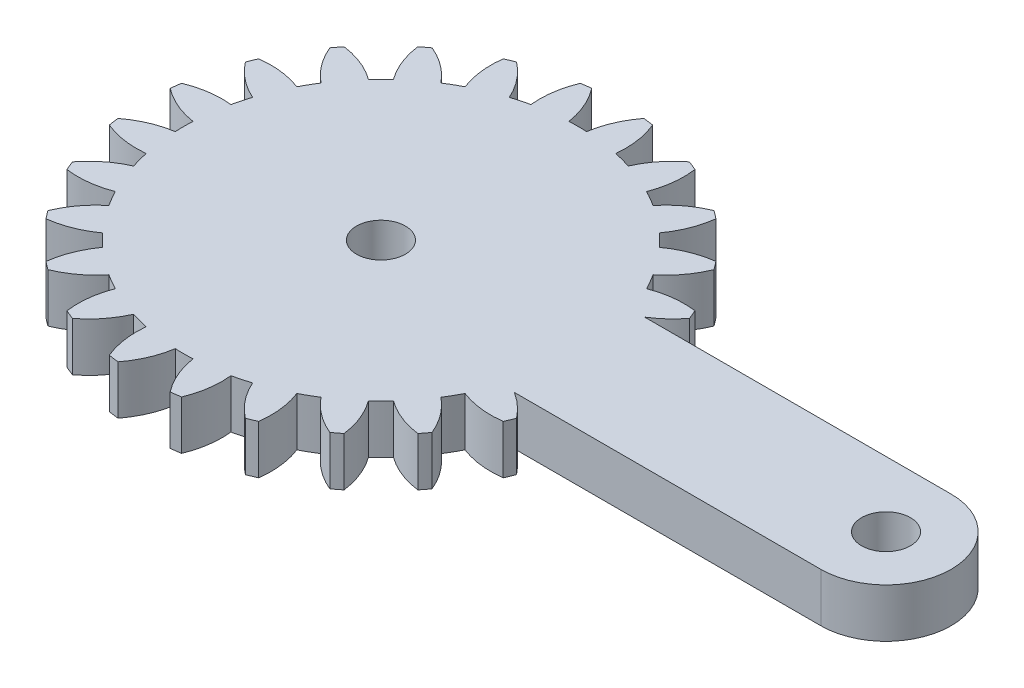
from build123d import *

# Parameters (mm, degrees)
SKETCH1_R           = 1.5
BOSS_EXTRUDE2_DEPTH = 3


with BuildPart() as part:
    # Sketch1 → Boss-Extrude2 (new body)
    with BuildSketch(Plane(origin=(0, 0, 0), x_dir=(1, 0, 0), z_dir=(0, 1, 0))):
        with BuildLine():
            Line((12.18798449, -4), (31, -4))
            ThreePointArc((31, -4), (35, 0), (31, 4))
            Line((31, 4), (12.18798449, 4))
            ThreePointArc((12.18798449, 4), (12.967370887, 4.588201733), (13.62809199, 5.30713988))
            ThreePointArc((13.62809199, 5.30713988), (13.511738163, 5.596745198), (13.389230859, 5.883801663))
            ThreePointArc((13.389230859, 5.883801663), (12.041618533, 5.894040025), (10.733437515, 5.57027124))
            ThreePointArc((10.733437515, 5.57027124), (10.472628702, 6.046375), (10.190715157, 6.510293938))
            ThreePointArc((10.190715157, 6.510293938), (11.125197659, 7.48132754), (11.79013714, 8.65351323))
            ThreePointArc((11.79013714, 8.65351323), (11.602792602, 8.903135899), (11.410163953, 9.148703928))
            ThreePointArc((11.410163953, 9.148703928), (10.105820521, 8.809805691), (8.926012217, 8.158486898))
            ThreePointArc((8.926012217, 8.158486898), (8.550865528, 8.550865528), (8.158486898, 8.926012217))
            ThreePointArc((8.158486898, 8.926012217), (8.809805691, 10.105820521), (9.148703928, 11.410163953))
            ThreePointArc((9.148703928, 11.410163953), (8.903135899, 11.602792602), (8.65351323, 11.79013714))
            ThreePointArc((8.65351323, 11.79013714), (7.48132754, 11.125197659), (6.510293938, 10.190715157))
            ThreePointArc((6.510293938, 10.190715157), (6.046375, 10.472628702), (5.57027124, 10.733437514))
            ThreePointArc((5.57027124, 10.733437514), (5.894040025, 12.041618533), (5.883801663, 13.389230859))
            ThreePointArc((5.883801663, 13.389230859), (5.596745198, 13.511738163), (5.30713988, 13.62809199))
            ThreePointArc((5.30713988, 13.62809199), (4.346994451, 12.682425791), (3.650909885, 11.528463019))
            ThreePointArc((3.650909885, 11.528463019), (3.129834008, 11.680699536), (2.602450802, 11.809396783))
            ThreePointArc((2.602450802, 11.809396783), (2.576605271, 13.156800143), (2.217928037, 14.455843809))
            ThreePointArc((2.217928037, 14.455843809), (1.908945561, 14.499881098), (1.599093719, 14.537314892))
            ThreePointArc((1.599093719, 14.537314892), (0.916420874, 13.375367565), (0.542722358, 12.080565177))
            ThreePointArc((0.542722358, 12.080565177), (0, 12.09275), (-0.542722358, 12.080565177))
            ThreePointArc((-0.542722358, 12.080565177), (-0.916420874, 13.375367565), (-1.599093719, 14.537314892))
            ThreePointArc((-1.599093719, 14.537314892), (-1.908945561, 14.499881098), (-2.217928037, 14.455843809))
            ThreePointArc((-2.217928037, 14.455843809), (-2.576605271, 13.156800143), (-2.602450802, 11.809396783))
            ThreePointArc((-2.602450802, 11.809396783), (-3.129834008, 11.680699536), (-3.650909885, 11.528463019))
            ThreePointArc((-3.650909885, 11.528463019), (-4.346994451, 12.682425791), (-5.30713988, 13.62809199))
            ThreePointArc((-5.30713988, 13.62809199), (-5.596745198, 13.511738163), (-5.883801663, 13.389230859))
            ThreePointArc((-5.883801663, 13.389230859), (-5.894040025, 12.041618533), (-5.57027124, 10.733437514))
            ThreePointArc((-5.57027124, 10.733437514), (-6.046375, 10.472628702), (-6.510293938, 10.190715157))
            ThreePointArc((-6.510293938, 10.190715157), (-7.48132754, 11.125197659), (-8.65351323, 11.79013714))
            ThreePointArc((-8.65351323, 11.79013714), (-8.903135899, 11.602792602), (-9.148703928, 11.410163953))
            ThreePointArc((-9.148703928, 11.410163953), (-8.809805691, 10.105820521), (-8.158486898, 8.926012217))
            ThreePointArc((-8.158486898, 8.926012217), (-8.550865528, 8.550865528), (-8.926012217, 8.158486898))
            ThreePointArc((-8.926012217, 8.158486898), (-10.105820521, 8.809805691), (-11.410163953, 9.148703928))
            ThreePointArc((-11.410163953, 9.148703928), (-11.602792602, 8.903135899), (-11.79013714, 8.65351323))
            ThreePointArc((-11.79013714, 8.65351323), (-11.125197659, 7.48132754), (-10.190715157, 6.510293938))
            ThreePointArc((-10.190715157, 6.510293938), (-10.472628702, 6.046375), (-10.733437515, 5.57027124))
            ThreePointArc((-10.733437515, 5.57027124), (-12.041618533, 5.894040025), (-13.389230859, 5.883801663))
            ThreePointArc((-13.389230859, 5.883801663), (-13.511738163, 5.596745198), (-13.62809199, 5.30713988))
            ThreePointArc((-13.62809199, 5.30713988), (-12.682425791, 4.346994451), (-11.528463019, 3.650909885))
            ThreePointArc((-11.528463019, 3.650909885), (-11.680699536, 3.129834008), (-11.809396783, 2.602450801))
            ThreePointArc((-11.809396783, 2.602450801), (-13.156800143, 2.576605271), (-14.455843809, 2.217928037))
            ThreePointArc((-14.455843809, 2.217928037), (-14.499881098, 1.908945561), (-14.537314892, 1.599093719))
            ThreePointArc((-14.537314892, 1.599093719), (-13.375367565, 0.916420874), (-12.080565177, 0.542722358))
            ThreePointArc((-12.080565177, 0.542722358), (-12.09275, 0), (-12.080565177, -0.542722358))
            ThreePointArc((-12.080565177, -0.542722358), (-13.375367565, -0.916420874), (-14.537314892, -1.599093719))
            ThreePointArc((-14.537314892, -1.599093719), (-14.499881098, -1.908945561), (-14.455843809, -2.217928037))
            ThreePointArc((-14.455843809, -2.217928037), (-13.156800143, -2.576605271), (-11.809396783, -2.602450801))
            ThreePointArc((-11.809396783, -2.602450801), (-11.680699536, -3.129834008), (-11.528463019, -3.650909885))
            ThreePointArc((-11.528463019, -3.650909885), (-12.682425791, -4.346994451), (-13.62809199, -5.30713988))
            ThreePointArc((-13.62809199, -5.30713988), (-13.511738163, -5.596745198), (-13.389230859, -5.883801663))
            ThreePointArc((-13.389230859, -5.883801663), (-12.041618533, -5.894040025), (-10.733437515, -5.57027124))
            ThreePointArc((-10.733437515, -5.57027124), (-10.472628702, -6.046375), (-10.190715157, -6.510293938))
            ThreePointArc((-10.190715157, -6.510293938), (-11.125197659, -7.48132754), (-11.79013714, -8.65351323))
            ThreePointArc((-11.79013714, -8.65351323), (-11.602792602, -8.903135899), (-11.410163953, -9.148703928))
            ThreePointArc((-11.410163953, -9.148703928), (-10.105820521, -8.809805691), (-8.926012217, -8.158486898))
            ThreePointArc((-8.926012217, -8.158486898), (-8.550865528, -8.550865528), (-8.158486898, -8.926012217))
            ThreePointArc((-8.158486898, -8.926012217), (-8.809805691, -10.105820521), (-9.148703928, -11.410163953))
            ThreePointArc((-9.148703928, -11.410163953), (-8.903135899, -11.602792602), (-8.65351323, -11.79013714))
            ThreePointArc((-8.65351323, -11.79013714), (-7.48132754, -11.125197659), (-6.510293938, -10.190715157))
            ThreePointArc((-6.510293938, -10.190715157), (-6.046375, -10.472628702), (-5.57027124, -10.733437514))
            ThreePointArc((-5.57027124, -10.733437514), (-5.894040025, -12.041618533), (-5.883801663, -13.389230859))
            ThreePointArc((-5.883801663, -13.389230859), (-5.596745198, -13.511738163), (-5.30713988, -13.62809199))
            ThreePointArc((-5.30713988, -13.62809199), (-4.346994451, -12.682425791), (-3.650909885, -11.528463019))
            ThreePointArc((-3.650909885, -11.528463019), (-3.129834008, -11.680699536), (-2.602450802, -11.809396783))
            ThreePointArc((-2.602450802, -11.809396783), (-2.576605271, -13.156800143), (-2.217928037, -14.455843809))
            ThreePointArc((-2.217928037, -14.455843809), (-1.908945561, -14.499881098), (-1.599093719, -14.537314892))
            ThreePointArc((-1.599093719, -14.537314892), (-0.916420874, -13.375367565), (-0.542722358, -12.080565177))
            ThreePointArc((-0.542722358, -12.080565177), (0, -12.09275), (0.542722358, -12.080565177))
            ThreePointArc((0.542722358, -12.080565177), (0.916420874, -13.375367565), (1.599093719, -14.537314892))
            ThreePointArc((1.599093719, -14.537314892), (1.908945561, -14.499881098), (2.217928037, -14.455843809))
            ThreePointArc((2.217928037, -14.455843809), (2.576605271, -13.156800143), (2.602450802, -11.809396783))
            ThreePointArc((2.602450802, -11.809396783), (3.129834008, -11.680699536), (3.650909885, -11.528463019))
            ThreePointArc((3.650909885, -11.528463019), (4.346994451, -12.682425791), (5.30713988, -13.62809199))
            ThreePointArc((5.30713988, -13.62809199), (5.596745198, -13.511738163), (5.883801663, -13.389230859))
            ThreePointArc((5.883801663, -13.389230859), (5.894040025, -12.041618533), (5.57027124, -10.733437514))
            ThreePointArc((5.57027124, -10.733437514), (6.046375, -10.472628702), (6.510293938, -10.190715157))
            ThreePointArc((6.510293938, -10.190715157), (7.48132754, -11.125197659), (8.65351323, -11.79013714))
            ThreePointArc((8.65351323, -11.79013714), (8.903135899, -11.602792602), (9.148703928, -11.410163953))
            ThreePointArc((9.148703928, -11.410163953), (8.809805691, -10.105820521), (8.158486898, -8.926012217))
            ThreePointArc((8.158486898, -8.926012217), (8.550865528, -8.550865528), (8.926012217, -8.158486898))
            ThreePointArc((8.926012217, -8.158486898), (10.105820521, -8.809805691), (11.410163953, -9.148703928))
            ThreePointArc((11.410163953, -9.148703928), (11.602792602, -8.903135899), (11.79013714, -8.65351323))
            ThreePointArc((11.79013714, -8.65351323), (11.125197659, -7.48132754), (10.190715157, -6.510293938))
            ThreePointArc((10.190715157, -6.510293938), (10.472628702, -6.046375), (10.733437515, -5.57027124))
            ThreePointArc((10.733437515, -5.57027124), (12.041618533, -5.894040025), (13.389230859, -5.883801663))
            ThreePointArc((13.389230859, -5.883801663), (13.511738163, -5.596745198), (13.62809199, -5.30713988))
            ThreePointArc((13.62809199, -5.30713988), (12.967370887, -4.588201733), (12.18798449, -4))
        make_face()
        with Locations((31, 0)):
            Circle(SKETCH1_R, mode=Mode.SUBTRACT)
        Circle(SKETCH1_R, mode=Mode.SUBTRACT)
    extrude(amount=BOSS_EXTRUDE2_DEPTH)


solid = part.part
